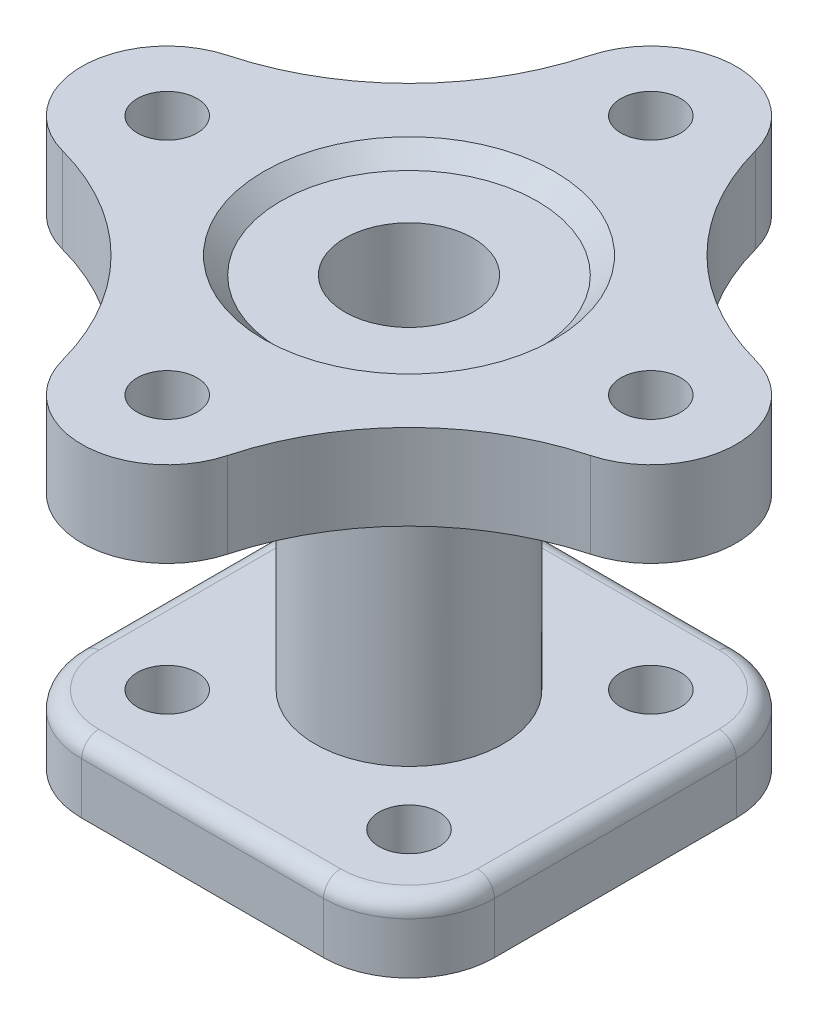
from build123d import *

# Parameters (mm, degrees)
SKETCH1_R           = 4.445
BOSS_EXTRUDE1_DEPTH = 10.16
FILLET1_R           = 2.54
SKETCH2_R           = 13.97
BOSS_EXTRUDE2_DEPTH = 43.18
SKETCH10_R          = 4.445
BOSS_EXTRUDE3_DEPTH = 12.7
SKETCH11_R          = 9.525
CUT_EXTRUDE1_DEPTH  = 67.04


with BuildPart() as part:
    # Sketch1 → Boss-Extrude1 (new body)
    with BuildSketch(Plane(origin=(0, 0, 0), x_dir=(1, 0, 0), z_dir=(0, 1, 0))):
        with BuildLine():
            Line((-17.960467, -30.660467), (17.960467, -30.660467))
            ThreePointArc((17.960467, -30.660467), (26.940723121, -26.940723121), (30.660467, -17.960467))
            Line((30.660467, -17.960467), (30.660467, 17.960467))
            ThreePointArc((30.660467, 17.960467), (26.940723121, 26.940723121), (17.960467, 30.660467))
            Line((17.960467, 30.660467), (-17.960467, 30.660467))
            ThreePointArc((-17.960467, 30.660467), (-26.940723121, 26.940723121), (-30.660467, 17.960467))
            Line((-30.660467, 17.960467), (-30.660467, -17.960467))
            ThreePointArc((-30.660467, -17.960467), (-26.940723121, -26.940723121), (-17.960467, -30.660467))
        make_face()
        with Locations((-17.960467, 17.960467)):
            Circle(SKETCH1_R, mode=Mode.SUBTRACT)
        with Locations((17.960467, 17.960467)):
            Circle(SKETCH1_R, mode=Mode.SUBTRACT)
        with Locations((-17.960467, -17.960467)):
            Circle(SKETCH1_R, mode=Mode.SUBTRACT)
        with Locations((17.960467, -17.960467)):
            Circle(SKETCH1_R, mode=Mode.SUBTRACT)
    extrude(amount=BOSS_EXTRUDE1_DEPTH)

    # Fillet1
    fillet1_edges = [part.edges().sort_by_distance(p)[0] for p in [
        (26.940723121, 10.16, 26.940723121),
        (30.660467, 10.16, 0),
        (26.940723121, 10.16, -26.940723121),
        (0, 10.16, -30.660467),
        (-26.940723121, 10.16, -26.940723121),
        (-30.660467, 10.16, 0),
        (-26.940723121, 10.16, 26.940723121),
        (0, 10.16, 30.660467),
    ]]
    fillet(fillet1_edges, radius=FILLET1_R)

    # Sketch2 → Boss-Extrude2 (add)
    with BuildSketch(Plane(origin=(0, 10.16, 0), x_dir=(1, 0, 0), z_dir=(0, 1, 0))):
        Circle(SKETCH2_R)
    extrude(amount=BOSS_EXTRUDE2_DEPTH)

    # Sketch10 → Boss-Extrude3 (add)
    with BuildSketch(Plane(origin=(0, 53.34, 0), x_dir=(1, 0, 0), z_dir=(0, 1, 0))):
        with BuildLine():
            ThreePointArc((-39.208026357, 12.267257994), (-48.621024484, 0), (-39.208026357, -12.267257994))
            ThreePointArc((-39.208026357, -12.267257994), (-22.128263612, -22.128263612), (-12.267257994, -39.208026357))
            ThreePointArc((-12.267257994, -39.208026357), (0, -48.621024484), (12.267257994, -39.208026357))
            ThreePointArc((12.267257994, -39.208026357), (22.128263612, -22.128263612), (39.208026357, -12.267257994))
            ThreePointArc((39.208026357, -12.267257994), (48.621024484, 0), (39.208026357, 12.267257994))
            ThreePointArc((39.208026357, 12.267257994), (22.128263612, 22.128263612), (12.267257994, 39.208026357))
            ThreePointArc((12.267257994, 39.208026357), (0, 48.621024484), (-12.267257994, 39.208026357))
            ThreePointArc((-12.267257994, 39.208026357), (-22.128263612, 22.128263612), (-39.208026357, 12.267257994))
        make_face()
        with Locations((-35.921024484, 0)):
            Circle(SKETCH10_R, mode=Mode.SUBTRACT)
        with Locations((0, 35.921024484)):
            Circle(SKETCH10_R, mode=Mode.SUBTRACT)
        with Locations((35.921024484, 0)):
            Circle(SKETCH10_R, mode=Mode.SUBTRACT)
        with Locations((0, -35.921024484)):
            Circle(SKETCH10_R, mode=Mode.SUBTRACT)
    extrude(amount=BOSS_EXTRUDE3_DEPTH)

    # Sketch11 → Cut-Extrude1 (cut, through all)
    with BuildSketch(Plane(origin=(0, 66.04, 0), x_dir=(1, 0, 0), z_dir=(0, 1, 0))):
        Circle(SKETCH11_R)
    extrude(amount=-CUT_EXTRUDE1_DEPTH, mode=Mode.SUBTRACT)

    # Sketch13 → Cut-Revolve1 (revolve, cut)
    with BuildSketch(Plane.XY):
        Polygon((21.59, 66.04), (19.05, 63.5), (0, 63.5), (0, 66.04), align=None)
    revolve(axis=Axis((0, 63.5, 0), (0, 1, 0)), mode=Mode.SUBTRACT)


solid = part.part
